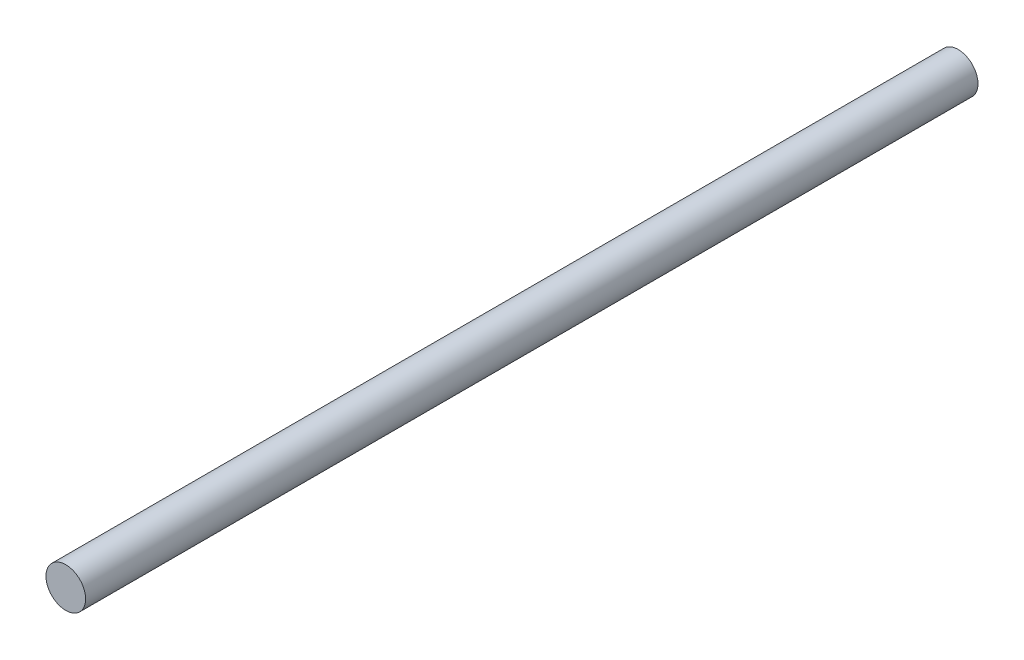
from build123d import *

# Parameters (mm, degrees)
CROQUIS1_R              = 10
SALIENTE_EXTRUIR2_DEPTH = 450


with BuildPart() as part:
    # Croquis1 → Saliente-Extruir2 (new body)
    with BuildSketch(Plane.XY):
        Circle(CROQUIS1_R)
    extrude(amount=SALIENTE_EXTRUIR2_DEPTH)


solid = part.part
